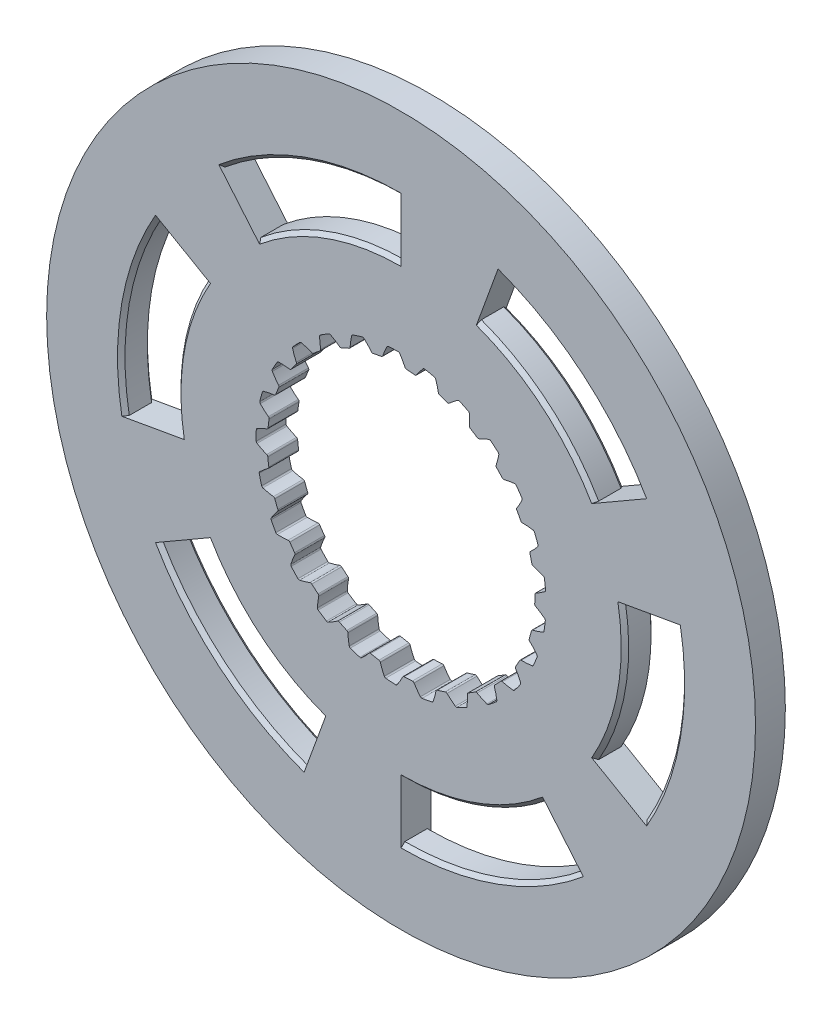
from build123d import *

# Parameters (mm, degrees)
SKETCH1_R                = 95
SKETCH1_R_2              = 35.85
BOSS_EXTRUDE1_DEPTH      = 8
CUT_EXTRUDE1_DEPTH       = 8
FILLET1_R                = 0.48
CIRPATTERN1_COUNT        = 25
FILLET1_OF_CIRPATTERN1_R = 0.48
CUT_EXTRUDE2_DEPTH       = 8
CHAMFER1_SIZE            = 1


with BuildPart() as part:
    # Sketch1 → Boss-Extrude1 (new body)
    with BuildSketch(Plane.XY):
        Circle(SKETCH1_R)
        Circle(SKETCH1_R_2, mode=Mode.SUBTRACT)
    extrude(amount=BOSS_EXTRUDE1_DEPTH)

    # Sketch2 → Cut-Extrude1 (cut)
    with BuildSketch(Plane.XY.offset(8)):
        with BuildLine():
            ThreePointArc((35.833660019, 1.082270585), (35.60665858, 4.169935824), (35.114102213, 7.226501628))
            add(Edge.make_bspline(
                [(35.114102213, 7.226501628), (35.256749104, 7.192417772), (35.550644487, 7.118209111), (35.992167201, 6.995069036), (36.581159742, 6.806547851), (37.167022559, 6.598198987), (37.692835452, 6.389637985), (38.059467989, 6.234671891), (38.285672809, 6.134159981), (38.368646366, 6.09667746)],
                knots=[0.310475903, 0.310475903, 0.310475903, 0.310475903, 0.310475903, 0.361767352, 0.41649966, 0.471231936, 0.525964282, 0.580696615, 0.612361314, 0.612361314, 0.612361314, 0.612361314, 0.612361314], degree=4))
            ThreePointArc((38.368646366, 6.09667746), (38.586295281, 4.518884429), (38.739090073, 2.933496259))
            add(Edge.make_bspline(
                [(35.833660019, 1.082270585), (35.964571851, 1.148391211), (36.233368583, 1.288497378), (36.634492244, 1.510320717), (37.163988833, 1.829829421), (37.685859134, 2.167906157), (38.149255382, 2.492314553), (38.470161804, 2.727799108), (38.667022153, 2.877856656), (38.739090073, 2.933496259)],
                knots=[0.310475903, 0.310475903, 0.310475903, 0.310475903, 0.310475903, 0.361767352, 0.41649966, 0.471231936, 0.525964282, 0.580696615, 0.612361314, 0.612361314, 0.612361314, 0.612361314, 0.612361314], degree=4))
        make_face()
    cut_extrude1 = extrude(amount=-CUT_EXTRUDE1_DEPTH, mode=Mode.SUBTRACT)

    # Fillet1
    fillet1_edges = [part.edges().sort_by_distance(p)[0] for p in [
        (35.833660019, 1.082270585, 4),
        (38.739090073, 2.933496259, 4),
        (35.114102213, 7.226501628, 4),
        (38.368646366, 6.09667746, 4),
    ]]
    fillet(fillet1_edges, radius=FILLET1_R)

    # CirPattern1: Cut-Extrude1 ×25 about axis
    cirpattern1_axis = Axis((0, 0, 8), (0, 0, -1))
    for i in range(1, CIRPATTERN1_COUNT):
        add(cut_extrude1.rotate(cirpattern1_axis, i * 360 / CIRPATTERN1_COUNT), mode=Mode.SUBTRACT)

    # Fillet1 of CirPattern1
    fillet1_of_cirpattern1_edges = [part.edges().sort_by_distance(p)[0] for p in [
        (34.977029446, -7.863199803, 4),
        (38.251561176, -6.79268486, 4),
        (35.808085996, -1.733054327, 4),
        (38.679406815, -3.636755209, 4),
        (31.922663476, -16.314596428, 4),
        (35.360546011, -16.092056607, 4),
        (34.252116043, -10.583716104, 4),
        (36.559797881, -13.141677173, 4),
        (26.862479156, -23.740886958, 4),
        (30.247697693, -24.380305254, 4),
        (30.543959669, -18.769364075, 4),
        (32.143002388, -21.820859229, 4),
        (20.114426478, -29.675450248, 4),
        (23.234275285, -31.136649659, 4),
        (24.916613975, -25.775663871, 4),
        (25.706543842, -29.128956447, 4),
        (12.102510409, -33.745395861, 4),
        (14.760957912, -35.936563853, 4),
        (17.723665789, -31.162383911, 4),
        (17.654848604, -34.606774203, 4),
        (3.3301491, -35.694994144, 4),
        (5.360155266, -38.478451574, 4),
        (9.417074498, -34.591056762, 4),
        (8.493834298, -37.910121062, 4),
        (-5.651457723, -35.401744669, 4),
        (-4.377445649, -38.602596669, 4),
        (0.518773783, -35.846246299, 4),
        (-1.200878854, -38.83143559, 4),
        (-14.277962674, -32.884073377, 4),
        (-13.839995554, -36.301198645, 4),
        (-8.412123397, -34.849084349, 4),
        (-10.820136372, -37.312828208, 4),
        (-22.007330719, -28.300174816, 4),
        (-22.432927639, -31.718862804, 4),
        (-16.814455926, -31.662226263, 4),
        (-19.759524928, -33.449718603, 4),
        (-28.353897238, -21.938072191, 4),
        (-29.616316377, -25.143514159, 4),
        (-24.16027435, -26.485914055, 4),
        (-27.457349862, -27.484840158, 4),
        (-32.918884114, -14.197519807, 4),
        (-34.938803037, -16.988306048, 4),
        (-29.988013882, -19.645394459, 4),
        (-33.429928524, -19.792988125, 4),
        (-35.415456435, -5.564885039, 4),
        (-38.065956205, -7.765660189, 4),
        (-33.931496213, -11.570482478, 4),
        (-37.301981829, -10.857469853, 4),
        (-35.686745379, 3.417411923, 4),
        (-38.801285349, 1.944930659, 4),
        (-35.742937845, -2.76855453, 4),
        (-38.830214429, -1.23973682, 4),
        (-33.715704864, 12.184980324, 4),
        (-37.098587033, 11.533314362, 4),
        (-35.30851924, 6.207331881, 4),
        (-37.918601849, 8.455893437, 4),
        (-29.626182615, 20.186921599, 4),
        (-33.064848054, 20.397017506, 4),
        (-32.655536515, 14.793188802, 4),
        (-34.62442406, 17.62020881, 4),
        (-23.675138355, 26.920444348, 4),
        (-26.953523069, 27.979101025, 4),
        (-27.950686332, 22.449535264, 4),
        (-29.154666367, 25.677381662, 4),
        (-16.23649808, 31.962456571, 4),
        (-19.148609101, 33.803154727, 4),
        (-21.489591732, 28.695294862, 4),
        (-21.853013764, 32.121150189, 4),
        (-7.777658918, 34.996150099, 4),
        (-10.140517599, 37.503231898, 4),
        (-13.67822705, 33.13802355, 4),
        (-13.178255935, 36.546628716, 4),
        (1.169879158, 35.830906809, 4),
        (-0.495260082, 38.846843082, 4),
        (-5.007409057, 35.498568345, 4),
        (-3.67545982, 38.675748152, 4),
        (10.043909424, 34.414275867, 4),
        (9.181116447, 37.749564246, 4),
        (3.978042863, 35.628607536, 4),
        (6.058278952, 38.374728092, 4),
        (18.286843923, 30.835269406, 4),
        (18.280609664, 34.280341456, 4),
        (12.713539719, 33.519970283, 4),
        (15.411353778, 35.662482734, 4),
        (25.380748763, 25.318769564, 4),
        (26.231464944, 28.657158737, 4),
        (20.650198118, 29.30515002, 4),
        (23.796076567, 30.709432428, 4),
        (30.879887815, 18.211398314, 4),
        (32.534100809, 21.233341342, 4),
        (27.289328623, 23.248979404, 4),
        (30.685604349, 23.826795541, 4),
        (34.438729947, 9.959737931, 4),
        (36.792499469, 12.475355019, 4),
        (32.213770247, 15.731989908, 4),
        (35.647042756, 15.447033462, 4),
    ]]
    fillet(fillet1_of_cirpattern1_edges, radius=FILLET1_OF_CIRPATTERN1_R)

    # Sketch3 → Cut-Extrude2 (cut)
    with BuildSketch(Plane.XY.offset(8)):
        with BuildLine():
            ThreePointArc((-38.567256581, 45.962666587), (-20.5212086, 56.381557247), (0, 60))
            Line((0, 60), (0, 75))
            ThreePointArc((0, 75), (-25.651510749, 70.476946559), (-48.209070726, 57.453333234))
            Line((-48.209070726, 57.453333234), (-38.567256581, 45.962666587))
        make_face()
        with BuildLine():
            Line((-73.860581476, -13.023613325), (-59.088465181, -10.41889066))
            ThreePointArc((-59.088465181, -10.41889066), (-59.088465181, 10.41889066), (-51.961524227, 30))
            Line((-51.961524227, 30), (-64.951905284, 37.5))
            ThreePointArc((-64.951905284, 37.5), (-73.860581476, 13.023613325), (-73.860581476, -13.023613325))
        make_face()
        with BuildLine():
            Line((-25.651510749, -70.476946559), (-20.5212086, -56.381557247))
            ThreePointArc((-20.5212086, -56.381557247), (-38.567256581, -45.962666587), (-51.961524227, -30))
            Line((-51.961524227, -30), (-64.951905284, -37.5))
            ThreePointArc((-64.951905284, -37.5), (-48.209070726, -57.453333234), (-25.651510749, -70.476946559))
        make_face()
        with BuildLine():
            Line((25.651510749, 70.476946559), (20.5212086, 56.381557247))
            ThreePointArc((20.5212086, 56.381557247), (38.567256581, 45.962666587), (51.961524227, 30))
            Line((51.961524227, 30), (64.951905284, 37.5))
            ThreePointArc((64.951905284, 37.5), (48.209070726, 57.453333234), (25.651510749, 70.476946559))
        make_face()
        with BuildLine():
            Line((73.860581476, 13.023613325), (59.088465181, 10.41889066))
            ThreePointArc((59.088465181, 10.41889066), (59.771681886, 5.229344565), (60, 0))
            ThreePointArc((60, 0), (57.955549577, -15.529142706), (51.961524227, -30))
            Line((51.961524227, -30), (64.951905284, -37.5))
            ThreePointArc((64.951905284, -37.5), (72.444436972, -19.411428383), (75, 0))
            ThreePointArc((75, 0), (74.714602357, 6.536680706), (73.860581476, 13.023613325))
        make_face()
        with BuildLine():
            Line((48.209070726, -57.453333234), (38.567256581, -45.962666587))
            ThreePointArc((38.567256581, -45.962666587), (20.5212086, -56.381557247), (0, -60))
            Line((0, -60), (0, -75))
            ThreePointArc((0, -75), (25.651510749, -70.476946559), (48.209070726, -57.453333234))
        make_face()
    extrude(amount=-CUT_EXTRUDE2_DEPTH, mode=Mode.SUBTRACT)

    # Chamfer1
    chamfer1_edges = [part.edges().sort_by_distance(p)[0] for p in [
        (-59.088465181, 10.41889066, 8),
        (-73.860581476, 13.023613325, 0),
        (-59.088465181, 10.41889066, 0),
        (-73.860581476, 13.023613325, 8),
        (-38.567256581, -45.962666587, 8),
        (-48.209070726, -57.453333234, 0),
        (-38.567256581, -45.962666587, 0),
        (-48.209070726, -57.453333234, 8),
        (38.567256581, 45.962666587, 8),
        (48.209070726, 57.453333234, 0),
        (38.567256581, 45.962666587, 0),
        (48.209070726, 57.453333234, 8),
        (59.088465181, -10.41889066, 8),
        (73.860581476, -13.023613325, 0),
        (59.088465181, -10.41889066, 0),
        (73.860581476, -13.023613325, 8),
        (20.5212086, -56.381557247, 8),
        (25.651510749, -70.476946559, 0),
        (20.5212086, -56.381557247, 0),
        (25.651510749, -70.476946559, 8),
        (-20.5212086, 56.381557247, 8),
        (-25.651510749, 70.476946559, 0),
        (-20.5212086, 56.381557247, 0),
        (-25.651510749, 70.476946559, 8),
    ]]
    chamfer(chamfer1_edges, length=CHAMFER1_SIZE)


solid = part.part
